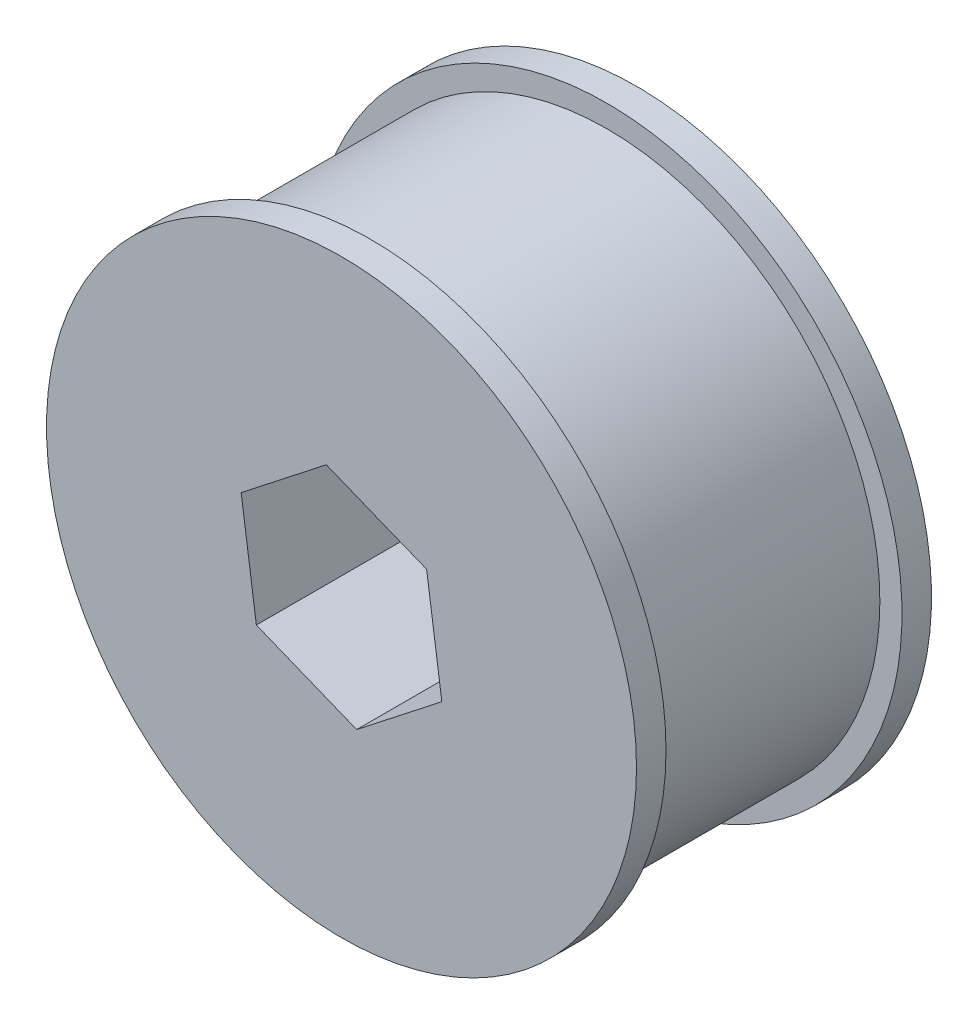
from build123d import *

# Parameters (mm, degrees)
SKETCH1_R           = 18.5
BOSS_EXTRUDE1_DEPTH = 20
SKETCH2_R           = 20
BOSS_EXTRUDE2_DEPTH = 2
SKETCH3_R           = 20
BOSS_EXTRUDE3_DEPTH = 2
CUT_EXTRUDE1_DEPTH  = 21


with BuildPart() as part:
    # Sketch1 → Boss-Extrude1 (new body)
    with BuildSketch(Plane.XY):
        Circle(SKETCH1_R)
    extrude(amount=BOSS_EXTRUDE1_DEPTH)

    # Sketch2 → Boss-Extrude2 (add)
    with BuildSketch(Plane.XY.offset(20)):
        Circle(SKETCH2_R)
    extrude(amount=-BOSS_EXTRUDE2_DEPTH)

    # Sketch3 → Boss-Extrude3 (add)
    with BuildSketch(Plane(origin=(0, 0, 0), x_dir=(-1, 0, 0), z_dir=(0, 0, -1))):
        Circle(SKETCH3_R)
    extrude(amount=-BOSS_EXTRUDE3_DEPTH)

    # Sketch4 → Cut-Extrude1 (cut, through all)
    with BuildSketch(Plane.XY.offset(20)):
        Polygon((5.772232155, 4.521578185), (-1.029685496, 7.259688775), (-6.801917651, 2.73811059), (-5.772232155, -4.521578185), (1.029685496, -7.259688775), (6.801917651, -2.73811059), align=None)
    extrude(amount=-CUT_EXTRUDE1_DEPTH, mode=Mode.SUBTRACT)


solid = part.part
